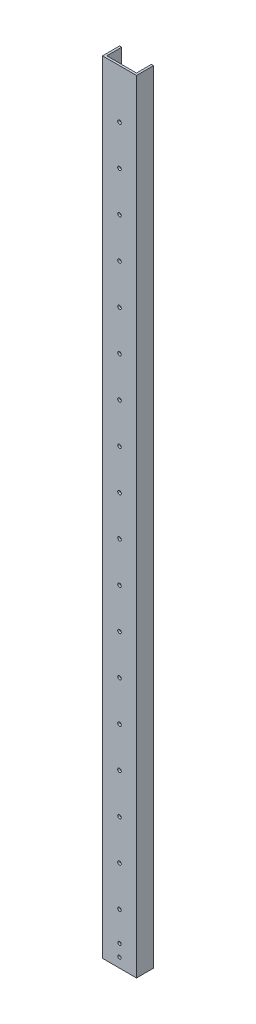
from build123d import *

# Parameters (mm, degrees)
BOSS_EXTRUDE1_DEPTH = 1168.4
CUT_EXTRUDE1_REACH  = 27.4
SKETCH2_R           = 2.667
CUT_EXTRUDE2_REACH  = 27.4
SKETCH3_R           = 2.5527


with BuildPart() as part:
    # Sketch1 → Boss-Extrude1 (new body)
    with BuildSketch(Plane(origin=(0, 0, 0), x_dir=(1, 0, 0), z_dir=(0, 1, 0))):
        Polygon((3.175, 3.175), (3.175, 25.4), (0, 25.4), (0, 0), (50.8, 0), (50.8, 25.4), (47.625, 25.4), (47.625, 3.175), align=None)
    extrude(amount=BOSS_EXTRUDE1_DEPTH)

    # Sketch2 → Cut-Extrude1 (cut, up to next)
    with BuildSketch(Plane.XY, mode=Mode.PRIVATE) as cut_extrude1_sk1:
        with Locations((25.4, 76.2)):
            Circle(SKETCH2_R)
    cut_extrude1_tool1 = extrude(cut_extrude1_sk1.sketch, amount=-CUT_EXTRUDE1_REACH, mode=Mode.PRIVATE) & part.part
    add(cut_extrude1_tool1.solids().sort_by_distance((25.4, 76.2, 0))[0], mode=Mode.SUBTRACT)
    # Sketch2 → Cut-Extrude1 (cut, up to next)
    with BuildSketch(Plane.XY, mode=Mode.PRIVATE) as cut_extrude1_sk2:
        with Locations((25.4, 136.144)):
            Circle(SKETCH2_R)
    cut_extrude1_tool2 = extrude(cut_extrude1_sk2.sketch, amount=-CUT_EXTRUDE1_REACH, mode=Mode.PRIVATE) & part.part
    add(cut_extrude1_tool2.solids().sort_by_distance((25.4, 136.144, 0))[0], mode=Mode.SUBTRACT)
    # Sketch2 → Cut-Extrude1 (cut, up to next)
    with BuildSketch(Plane.XY, mode=Mode.PRIVATE) as cut_extrude1_sk3:
        with Locations((25.4, 196.088)):
            Circle(SKETCH2_R)
    cut_extrude1_tool3 = extrude(cut_extrude1_sk3.sketch, amount=-CUT_EXTRUDE1_REACH, mode=Mode.PRIVATE) & part.part
    add(cut_extrude1_tool3.solids().sort_by_distance((25.4, 196.088, 0))[0], mode=Mode.SUBTRACT)
    # Sketch2 → Cut-Extrude1 (cut, up to next)
    with BuildSketch(Plane.XY, mode=Mode.PRIVATE) as cut_extrude1_sk4:
        with Locations((25.4, 256.032)):
            Circle(SKETCH2_R)
    cut_extrude1_tool4 = extrude(cut_extrude1_sk4.sketch, amount=-CUT_EXTRUDE1_REACH, mode=Mode.PRIVATE) & part.part
    add(cut_extrude1_tool4.solids().sort_by_distance((25.4, 256.032, 0))[0], mode=Mode.SUBTRACT)
    # Sketch2 → Cut-Extrude1 (cut, up to next)
    with BuildSketch(Plane.XY, mode=Mode.PRIVATE) as cut_extrude1_sk5:
        with Locations((25.4, 315.976)):
            Circle(SKETCH2_R)
    cut_extrude1_tool5 = extrude(cut_extrude1_sk5.sketch, amount=-CUT_EXTRUDE1_REACH, mode=Mode.PRIVATE) & part.part
    add(cut_extrude1_tool5.solids().sort_by_distance((25.4, 315.976, 0))[0], mode=Mode.SUBTRACT)
    # Sketch2 → Cut-Extrude1 (cut, up to next)
    with BuildSketch(Plane.XY, mode=Mode.PRIVATE) as cut_extrude1_sk6:
        with Locations((25.4, 375.92)):
            Circle(SKETCH2_R)
    cut_extrude1_tool6 = extrude(cut_extrude1_sk6.sketch, amount=-CUT_EXTRUDE1_REACH, mode=Mode.PRIVATE) & part.part
    add(cut_extrude1_tool6.solids().sort_by_distance((25.4, 375.92, 0))[0], mode=Mode.SUBTRACT)
    # Sketch2 → Cut-Extrude1 (cut, up to next)
    with BuildSketch(Plane.XY, mode=Mode.PRIVATE) as cut_extrude1_sk7:
        with Locations((25.4, 435.864)):
            Circle(SKETCH2_R)
    cut_extrude1_tool7 = extrude(cut_extrude1_sk7.sketch, amount=-CUT_EXTRUDE1_REACH, mode=Mode.PRIVATE) & part.part
    add(cut_extrude1_tool7.solids().sort_by_distance((25.4, 435.864, 0))[0], mode=Mode.SUBTRACT)
    # Sketch2 → Cut-Extrude1 (cut, up to next)
    with BuildSketch(Plane.XY, mode=Mode.PRIVATE) as cut_extrude1_sk8:
        with Locations((25.4, 495.808)):
            Circle(SKETCH2_R)
    cut_extrude1_tool8 = extrude(cut_extrude1_sk8.sketch, amount=-CUT_EXTRUDE1_REACH, mode=Mode.PRIVATE) & part.part
    add(cut_extrude1_tool8.solids().sort_by_distance((25.4, 495.808, 0))[0], mode=Mode.SUBTRACT)
    # Sketch2 → Cut-Extrude1 (cut, up to next)
    with BuildSketch(Plane.XY, mode=Mode.PRIVATE) as cut_extrude1_sk9:
        with Locations((25.4, 555.752)):
            Circle(SKETCH2_R)
    cut_extrude1_tool9 = extrude(cut_extrude1_sk9.sketch, amount=-CUT_EXTRUDE1_REACH, mode=Mode.PRIVATE) & part.part
    add(cut_extrude1_tool9.solids().sort_by_distance((25.4, 555.752, 0))[0], mode=Mode.SUBTRACT)
    # Sketch2 → Cut-Extrude1 (cut, up to next)
    with BuildSketch(Plane.XY, mode=Mode.PRIVATE) as cut_extrude1_sk10:
        with Locations((25.4, 615.696)):
            Circle(SKETCH2_R)
    cut_extrude1_tool10 = extrude(cut_extrude1_sk10.sketch, amount=-CUT_EXTRUDE1_REACH, mode=Mode.PRIVATE) & part.part
    add(cut_extrude1_tool10.solids().sort_by_distance((25.4, 615.696, 0))[0], mode=Mode.SUBTRACT)
    # Sketch2 → Cut-Extrude1 (cut, up to next)
    with BuildSketch(Plane.XY, mode=Mode.PRIVATE) as cut_extrude1_sk11:
        with Locations((25.4, 675.64)):
            Circle(SKETCH2_R)
    cut_extrude1_tool11 = extrude(cut_extrude1_sk11.sketch, amount=-CUT_EXTRUDE1_REACH, mode=Mode.PRIVATE) & part.part
    add(cut_extrude1_tool11.solids().sort_by_distance((25.4, 675.64, 0))[0], mode=Mode.SUBTRACT)
    # Sketch2 → Cut-Extrude1 (cut, up to next)
    with BuildSketch(Plane.XY, mode=Mode.PRIVATE) as cut_extrude1_sk12:
        with Locations((25.4, 735.584)):
            Circle(SKETCH2_R)
    cut_extrude1_tool12 = extrude(cut_extrude1_sk12.sketch, amount=-CUT_EXTRUDE1_REACH, mode=Mode.PRIVATE) & part.part
    add(cut_extrude1_tool12.solids().sort_by_distance((25.4, 735.584, 0))[0], mode=Mode.SUBTRACT)
    # Sketch2 → Cut-Extrude1 (cut, up to next)
    with BuildSketch(Plane.XY, mode=Mode.PRIVATE) as cut_extrude1_sk13:
        with Locations((25.4, 795.528)):
            Circle(SKETCH2_R)
    cut_extrude1_tool13 = extrude(cut_extrude1_sk13.sketch, amount=-CUT_EXTRUDE1_REACH, mode=Mode.PRIVATE) & part.part
    add(cut_extrude1_tool13.solids().sort_by_distance((25.4, 795.528, 0))[0], mode=Mode.SUBTRACT)
    # Sketch2 → Cut-Extrude1 (cut, up to next)
    with BuildSketch(Plane.XY, mode=Mode.PRIVATE) as cut_extrude1_sk14:
        with Locations((25.4, 855.472)):
            Circle(SKETCH2_R)
    cut_extrude1_tool14 = extrude(cut_extrude1_sk14.sketch, amount=-CUT_EXTRUDE1_REACH, mode=Mode.PRIVATE) & part.part
    add(cut_extrude1_tool14.solids().sort_by_distance((25.4, 855.472, 0))[0], mode=Mode.SUBTRACT)
    # Sketch2 → Cut-Extrude1 (cut, up to next)
    with BuildSketch(Plane.XY, mode=Mode.PRIVATE) as cut_extrude1_sk15:
        with Locations((25.4, 915.416)):
            Circle(SKETCH2_R)
    cut_extrude1_tool15 = extrude(cut_extrude1_sk15.sketch, amount=-CUT_EXTRUDE1_REACH, mode=Mode.PRIVATE) & part.part
    add(cut_extrude1_tool15.solids().sort_by_distance((25.4, 915.416, 0))[0], mode=Mode.SUBTRACT)
    # Sketch2 → Cut-Extrude1 (cut, up to next)
    with BuildSketch(Plane.XY, mode=Mode.PRIVATE) as cut_extrude1_sk16:
        with Locations((25.4, 975.36)):
            Circle(SKETCH2_R)
    cut_extrude1_tool16 = extrude(cut_extrude1_sk16.sketch, amount=-CUT_EXTRUDE1_REACH, mode=Mode.PRIVATE) & part.part
    add(cut_extrude1_tool16.solids().sort_by_distance((25.4, 975.36, 0))[0], mode=Mode.SUBTRACT)
    # Sketch2 → Cut-Extrude1 (cut, up to next)
    with BuildSketch(Plane.XY, mode=Mode.PRIVATE) as cut_extrude1_sk17:
        with Locations((25.4, 1035.304)):
            Circle(SKETCH2_R)
    cut_extrude1_tool17 = extrude(cut_extrude1_sk17.sketch, amount=-CUT_EXTRUDE1_REACH, mode=Mode.PRIVATE) & part.part
    add(cut_extrude1_tool17.solids().sort_by_distance((25.4, 1035.304, 0))[0], mode=Mode.SUBTRACT)
    # Sketch2 → Cut-Extrude1 (cut, up to next)
    with BuildSketch(Plane.XY, mode=Mode.PRIVATE) as cut_extrude1_sk18:
        with Locations((25.4, 1095.248)):
            Circle(SKETCH2_R)
    cut_extrude1_tool18 = extrude(cut_extrude1_sk18.sketch, amount=-CUT_EXTRUDE1_REACH, mode=Mode.PRIVATE) & part.part
    add(cut_extrude1_tool18.solids().sort_by_distance((25.4, 1095.248, 0))[0], mode=Mode.SUBTRACT)

    # Sketch3 → Cut-Extrude2 (cut, up to next)
    with BuildSketch(Plane.XY, mode=Mode.PRIVATE) as cut_extrude2_sk1:
        with Locations((25.4, 32.131)):
            Circle(SKETCH3_R)
    cut_extrude2_tool1 = extrude(cut_extrude2_sk1.sketch, amount=-CUT_EXTRUDE2_REACH, mode=Mode.PRIVATE) & part.part
    add(cut_extrude2_tool1.solids().sort_by_distance((25.4, 32.131, 0))[0], mode=Mode.SUBTRACT)
    # Sketch3 → Cut-Extrude2 (cut, up to next)
    with BuildSketch(Plane.XY, mode=Mode.PRIVATE) as cut_extrude2_sk2:
        with Locations((25.4, 14.2875)):
            Circle(SKETCH3_R)
    cut_extrude2_tool2 = extrude(cut_extrude2_sk2.sketch, amount=-CUT_EXTRUDE2_REACH, mode=Mode.PRIVATE) & part.part
    add(cut_extrude2_tool2.solids().sort_by_distance((25.4, 14.2875, 0))[0], mode=Mode.SUBTRACT)


solid = part.part
